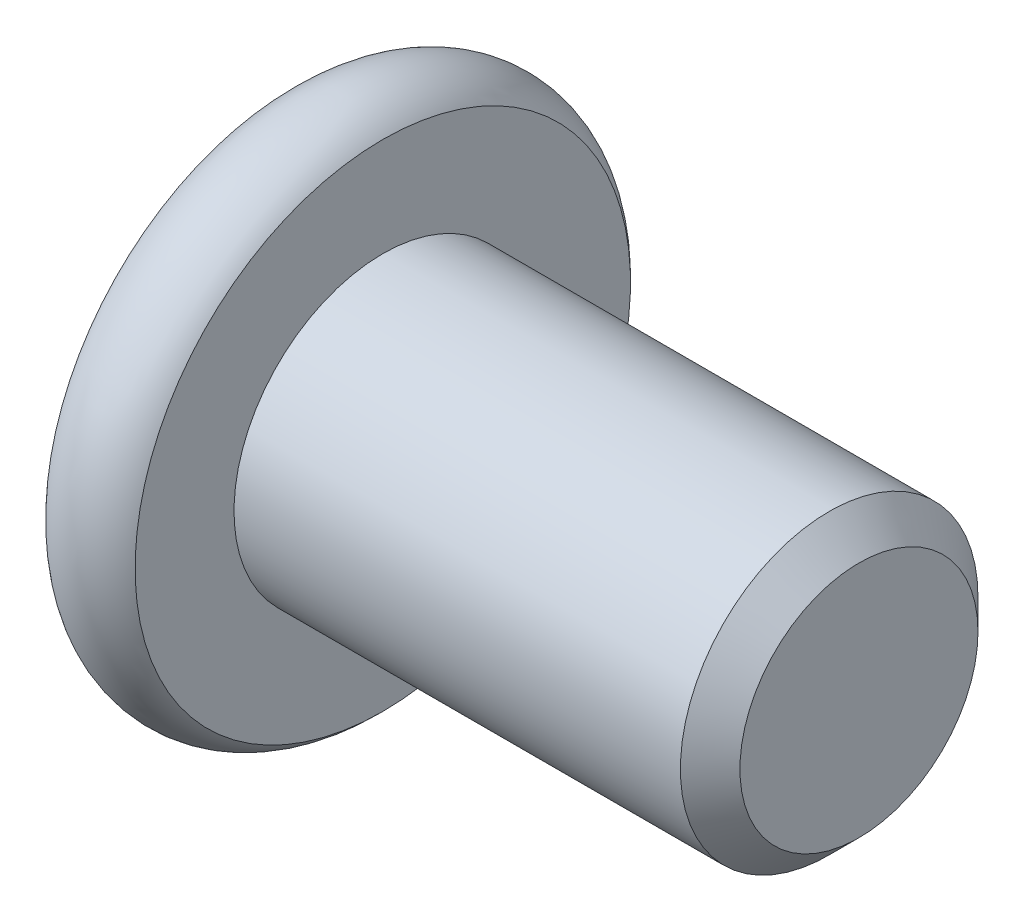
from build123d import *

# Parameters (mm, degrees)
SKETCH2_R           = 2.5
BOSS_EXTRUDE1_DEPTH = 8
CHAMFER1_SIZE       = 0.5
CUT_EXTRUDE1_DEPTH  = 2.3
SKETCH8_R           = 1.782050808
CUT_EXTRUDE2_DEPTH  = 1
CUT_EXTRUDE2_TAPER  = 45


with BuildPart() as part:
    # Sketch2 → Boss-Extrude1 (new body)
    with BuildSketch(Plane(origin=(0, 0, 0), x_dir=(0, 0, -1), z_dir=(1, 0, 0))):
        Circle(SKETCH2_R)
    extrude(amount=-BOSS_EXTRUDE1_DEPTH)

    # Chamfer1
    chamfer1_edges = [part.edges().sort_by_distance(p)[0] for p in [
        (0, 0, 2.5),
    ]]
    chamfer(chamfer1_edges, length=CHAMFER1_SIZE)

    # Sketch6 → Revolve1 (revolve)
    with BuildSketch(Plane.XY):
        with BuildLine():
            Line((-9.5, 0), (-9.5, 4.161437828))
            ThreePointArc((-9.5, 4.161437828), (-8.75, 4.5), (-8, 4.161437828))
            Line((-8, 4.161437828), (-8, 0))
            Line((-8, 0), (-9.5, 0))
        make_face()
    revolve(axis=Axis((-8, 0, 0), (-1, 0, 0)))

    # Sketch7 → Cut-Extrude1 (cut)
    with BuildSketch(Plane.ZY.offset(9.5)):
        Polygon((0, 1.732050808), (-1.5, 0.866025404), (-1.5, -0.866025404), (0, -1.732050808), (1.5, -0.866025404), (1.5, 0.866025404), align=None)
    extrude(amount=-CUT_EXTRUDE1_DEPTH, mode=Mode.SUBTRACT)

    # Sketch8 → Cut-Extrude2 (cut)
    with BuildSketch(Plane.ZY.offset(9.5)):
        Circle(SKETCH8_R)
    extrude(amount=-CUT_EXTRUDE2_DEPTH, taper=CUT_EXTRUDE2_TAPER, mode=Mode.SUBTRACT)


solid = part.part
